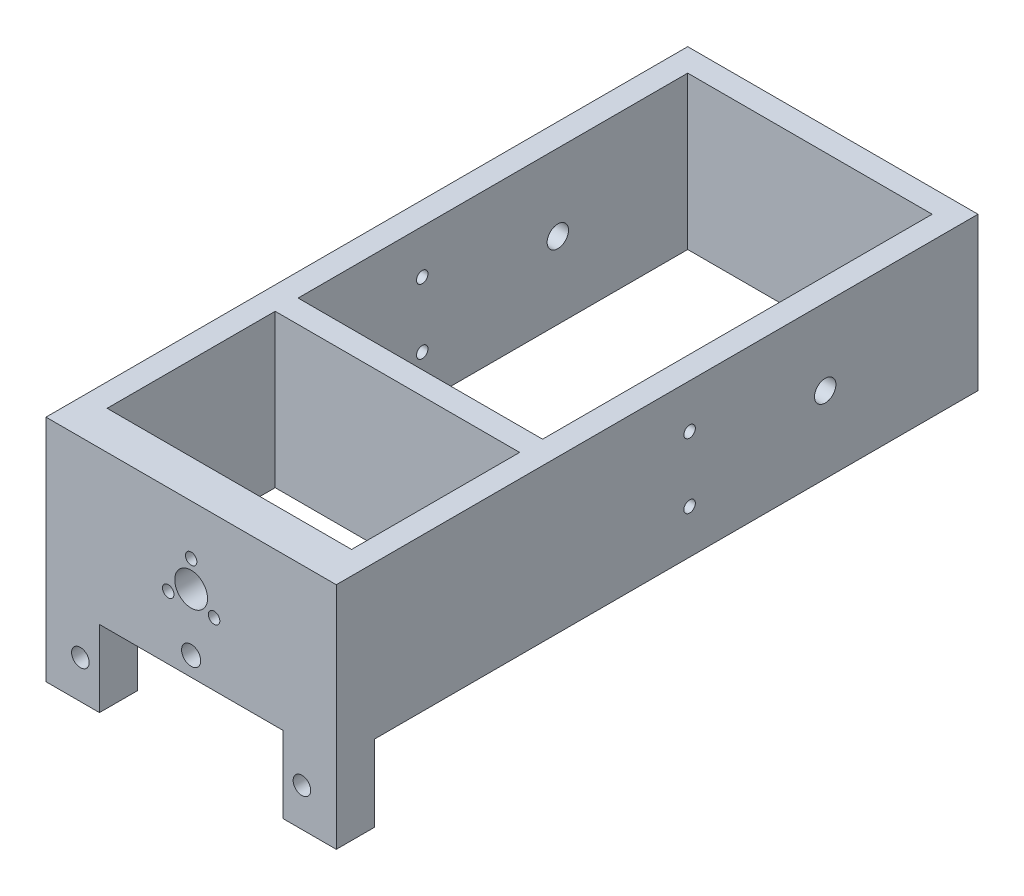
from build123d import *

# Parameters (mm, degrees)
ESBO_O2_W                = 84
ESBO_O2_H                = 20
ESBO_O2_R                = 0.75
ESBO_O2_R_2              = 1.4
RESSALTO_EXTRUS_O1_DEPTH = 19
ESBO_O3_W                = 32
ESBO_O3_H                = 51
ESBO_O3_H_2              = 22
CORTE_EXTRUS_O1_DEPTH    = 21
ESBO_O6_W                = 7
ESBO_O6_H                = 5
RESSALTO_EXTRUS_O2_DEPTH = 10
CORTE_EXTRUS_O2_REACH    = 86
ESBO_O4_R                = 0.75
ESBO_O4_R_2              = 1.25
ESBO_O4_R_3              = 2.15
ESBO_O4_R_4              = 1.15


with BuildPart() as part:
    # Esboço2 → Ressalto-extrusão1 (new body, symmetric)
    with BuildSketch(Plane(origin=(0, 0, 0), x_dir=(0, 0, -1), z_dir=(1, 0, 0))):
        with Locations((-2, 0)):
            Rectangle(ESBO_O2_W, ESBO_O2_H)
        with Locations((2.25, 4.25)):
            Circle(ESBO_O2_R, mode=Mode.SUBTRACT)
        with Locations((2.25, -4.25)):
            Circle(ESBO_O2_R, mode=Mode.SUBTRACT)
        with Locations((20, 0)):
            Circle(ESBO_O2_R_2, mode=Mode.SUBTRACT)
    extrude(amount=RESSALTO_EXTRUS_O1_DEPTH, both=True)

    # Esboço3 → Corte-extrusão1 (cut, through all)
    with BuildSketch(Plane(origin=(0, 10, 0), x_dir=(1, 0, 0), z_dir=(0, 1, 0))):
        with Locations((0, 11.5)):
            Rectangle(ESBO_O3_W, ESBO_O3_H)
        with Locations((0, -28)):
            Rectangle(ESBO_O3_W, ESBO_O3_H_2)
    extrude(amount=-CORTE_EXTRUS_O1_DEPTH, mode=Mode.SUBTRACT)

    # Esboço6 → Ressalto-extrusão2 (add)
    with BuildSketch(Plane.XZ.offset(10)):
        with Locations((-15.5, 41.5)):
            Rectangle(ESBO_O6_W, ESBO_O6_H)
        with Locations((15.5, 41.5)):
            Rectangle(ESBO_O6_W, ESBO_O6_H)
    extrude(amount=RESSALTO_EXTRUS_O2_DEPTH)

    # Esboço4 → Corte-extrusão2 (cut, up to next)
    with BuildSketch(Plane.XY.offset(44), mode=Mode.PRIVATE) as corte_extrus_o2_sk1:
        with Locations((0, 3.464101615)):
            Circle(ESBO_O4_R)
    corte_extrus_o2_tool1 = extrude(corte_extrus_o2_sk1.sketch, amount=-CORTE_EXTRUS_O2_REACH, mode=Mode.PRIVATE) & part.part
    add(corte_extrus_o2_tool1.solids().sort_by_distance((0, 3.464102, 44))[0], mode=Mode.SUBTRACT)
    # Esboço4 → Corte-extrusão2 (cut, up to next)
    with BuildSketch(Plane.XY.offset(44), mode=Mode.PRIVATE) as corte_extrus_o2_sk2:
        with Locations((3, -1.732050808)):
            Circle(ESBO_O4_R)
    corte_extrus_o2_tool2 = extrude(corte_extrus_o2_sk2.sketch, amount=-CORTE_EXTRUS_O2_REACH, mode=Mode.PRIVATE) & part.part
    add(corte_extrus_o2_tool2.solids().sort_by_distance((3, -1.732051, 44))[0], mode=Mode.SUBTRACT)
    # Esboço4 → Corte-extrusão2 (cut, up to next)
    with BuildSketch(Plane.XY.offset(44), mode=Mode.PRIVATE) as corte_extrus_o2_sk3:
        with Locations((-3, -1.732050808)):
            Circle(ESBO_O4_R)
    corte_extrus_o2_tool3 = extrude(corte_extrus_o2_sk3.sketch, amount=-CORTE_EXTRUS_O2_REACH, mode=Mode.PRIVATE) & part.part
    add(corte_extrus_o2_tool3.solids().sort_by_distance((-3, -1.732051, 44))[0], mode=Mode.SUBTRACT)
    # Esboço4 → Corte-extrusão2 (cut, up to next)
    with BuildSketch(Plane.XY.offset(44), mode=Mode.PRIVATE) as corte_extrus_o2_sk4:
        with Locations((0, -7.5)):
            Circle(ESBO_O4_R_2)
    corte_extrus_o2_tool4 = extrude(corte_extrus_o2_sk4.sketch, amount=-CORTE_EXTRUS_O2_REACH, mode=Mode.PRIVATE) & part.part
    add(corte_extrus_o2_tool4.solids().sort_by_distance((0, -7.5, 44))[0], mode=Mode.SUBTRACT)
    # Esboço4 → Corte-extrusão2 (cut, up to next)
    with BuildSketch(Plane.XY.offset(44), mode=Mode.PRIVATE) as corte_extrus_o2_sk5:
        Circle(ESBO_O4_R_3)
    corte_extrus_o2_tool5 = extrude(corte_extrus_o2_sk5.sketch, amount=-CORTE_EXTRUS_O2_REACH, mode=Mode.PRIVATE) & part.part
    add(corte_extrus_o2_tool5.solids().sort_by_distance((0, 0, 44))[0], mode=Mode.SUBTRACT)
    # Esboço4 → Corte-extrusão2 (cut, up to next)
    with BuildSketch(Plane.XY.offset(44), mode=Mode.PRIVATE) as corte_extrus_o2_sk6:
        with Locations((-14.5, -15)):
            Circle(ESBO_O4_R_4)
    corte_extrus_o2_tool6 = extrude(corte_extrus_o2_sk6.sketch, amount=-CORTE_EXTRUS_O2_REACH, mode=Mode.PRIVATE) & part.part
    add(corte_extrus_o2_tool6.solids().sort_by_distance((-14.5, -15, 44))[0], mode=Mode.SUBTRACT)
    # Esboço4 → Corte-extrusão2 (cut, up to next)
    with BuildSketch(Plane.XY.offset(44), mode=Mode.PRIVATE) as corte_extrus_o2_sk7:
        with Locations((14.5, -15)):
            Circle(ESBO_O4_R_4)
    corte_extrus_o2_tool7 = extrude(corte_extrus_o2_sk7.sketch, amount=-CORTE_EXTRUS_O2_REACH, mode=Mode.PRIVATE) & part.part
    add(corte_extrus_o2_tool7.solids().sort_by_distance((14.5, -15, 44))[0], mode=Mode.SUBTRACT)


solid = part.part
